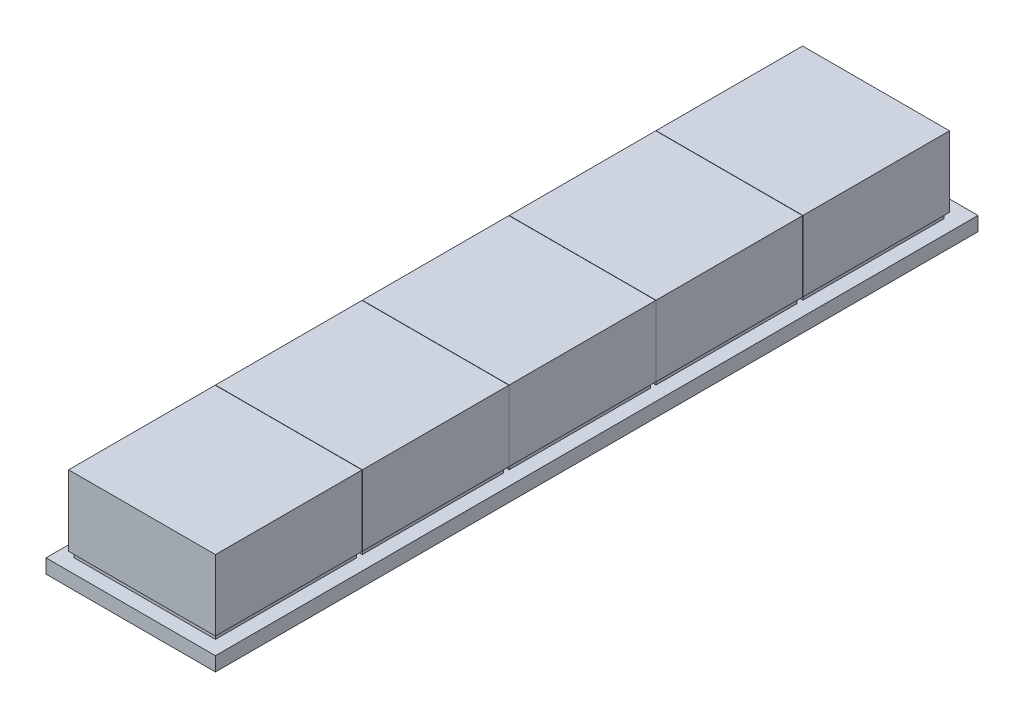
from build123d import *

# Parameters (mm, degrees)
SKETCH1_W           = 60
SKETCH1_H           = 270
BOSS_EXTRUDE1_DEPTH = 5
SKETCH2_W           = 50
SKETCH2_H           = 50
BOSS_EXTRUDE3_DEPTH = 2
LPATTERN1_COUNT     = 5
LPATTERN1_PITCH     = 52
SKETCH3_W           = 52
SKETCH3_H           = 51.9
BOSS_EXTRUDE8_DEPTH = 25
LPATTERN5_COUNT     = 5
LPATTERN5_PITCH     = 52


with BuildPart() as part:
    # Sketch1 → Boss-Extrude1 (new body)
    with BuildSketch(Plane(origin=(0, 0, 0), x_dir=(1, 0, 0), z_dir=(0, 1, 0))):
        Rectangle(SKETCH1_W, SKETCH1_H)
    extrude(amount=BOSS_EXTRUDE1_DEPTH)

    # Sketch2 → Boss-Extrude3 (add)
    with BuildSketch(Plane(origin=(0, 5, 0), x_dir=(1, 0, 0), z_dir=(0, 1, 0))):
        with Locations((0, -105)):
            Rectangle(SKETCH2_W, SKETCH2_H)
    boss_extrude3 = extrude(amount=BOSS_EXTRUDE3_DEPTH)

    # LPattern1: Boss-Extrude3 ×5
    with Locations(*[(0, 0, -i * LPATTERN1_PITCH) for i in range(1, LPATTERN1_COUNT)]):
        add(boss_extrude3)

    # Sketch3 → Boss-Extrude8 (add)
    with BuildSketch(Plane(origin=(0, 7, 0), x_dir=(1, 0, 0), z_dir=(0, 1, 0))):
        with Locations((0, -105.05)):
            Rectangle(SKETCH3_W, SKETCH3_H)
    boss_extrude8 = extrude(amount=BOSS_EXTRUDE8_DEPTH)

    # LPattern5: Boss-Extrude8 ×5
    with Locations(*[(0, 0, -i * LPATTERN5_PITCH) for i in range(1, LPATTERN5_COUNT)]):
        add(boss_extrude8)


solid = part.part
